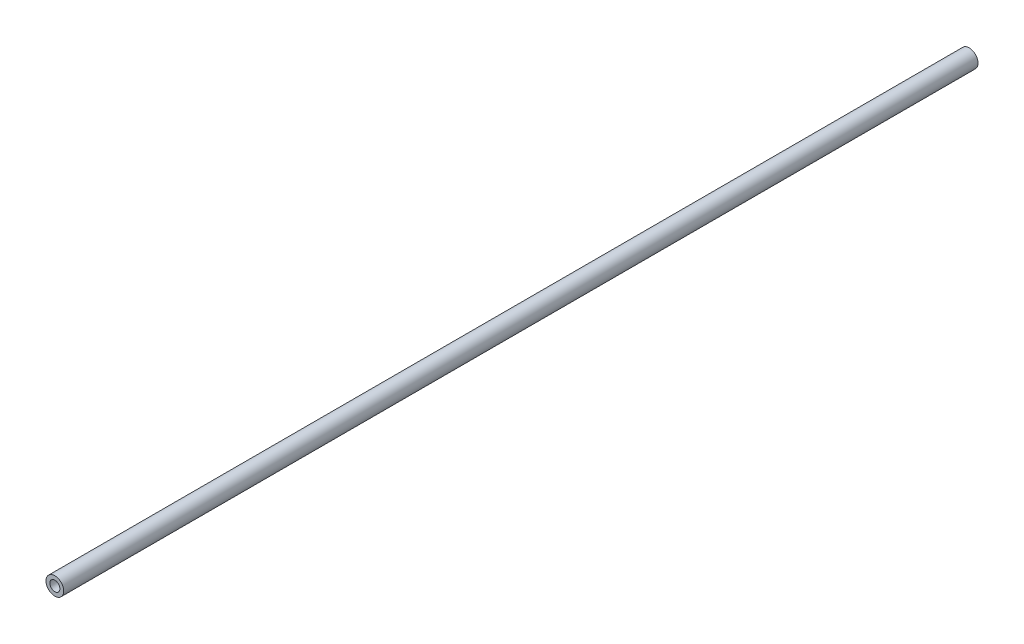
from build123d import *

# Parameters (mm, degrees)
CROQUIS1_R                = 6
SALIENTE_EXTRUIR1_DEPTH   = 620
TALADRO_ROSCADO_M81_D     = 6.8
TALADRO_ROSCADO_M81_DEPTH = 30
TALADRO_ROSCADO_M81_TIP   = 2.042926105
TALADRO_ROSCADO_M82_D     = 6.8
TALADRO_ROSCADO_M82_DEPTH = 30
TALADRO_ROSCADO_M82_TIP   = 2.042926105


with BuildPart() as part:
    # Croquis1 → Saliente-Extruir1 (new body)
    with BuildSketch(Plane.XY):
        Circle(CROQUIS1_R)
    extrude(amount=SALIENTE_EXTRUIR1_DEPTH)

    # Taladro roscado M81
    with Locations(Plane.XY.offset(620)):
        with Locations((0, 0)):
            Hole(TALADRO_ROSCADO_M81_D / 2, depth=TALADRO_ROSCADO_M81_DEPTH)
            with Locations((0, 0, -(TALADRO_ROSCADO_M81_DEPTH + TALADRO_ROSCADO_M81_TIP / 2))):  # 118° drill point
                Cone(0, TALADRO_ROSCADO_M81_D / 2, TALADRO_ROSCADO_M81_TIP, mode=Mode.SUBTRACT)

    # Taladro roscado M82
    with Locations(Plane(origin=(0, 0, 0), x_dir=(-1, 0, 0), z_dir=(0, 0, -1))):
        with Locations((0, 0)):
            Hole(TALADRO_ROSCADO_M82_D / 2, depth=TALADRO_ROSCADO_M82_DEPTH)
            with Locations((0, 0, -(TALADRO_ROSCADO_M82_DEPTH + TALADRO_ROSCADO_M82_TIP / 2))):  # 118° drill point
                Cone(0, TALADRO_ROSCADO_M82_D / 2, TALADRO_ROSCADO_M82_TIP, mode=Mode.SUBTRACT)


solid = part.part
